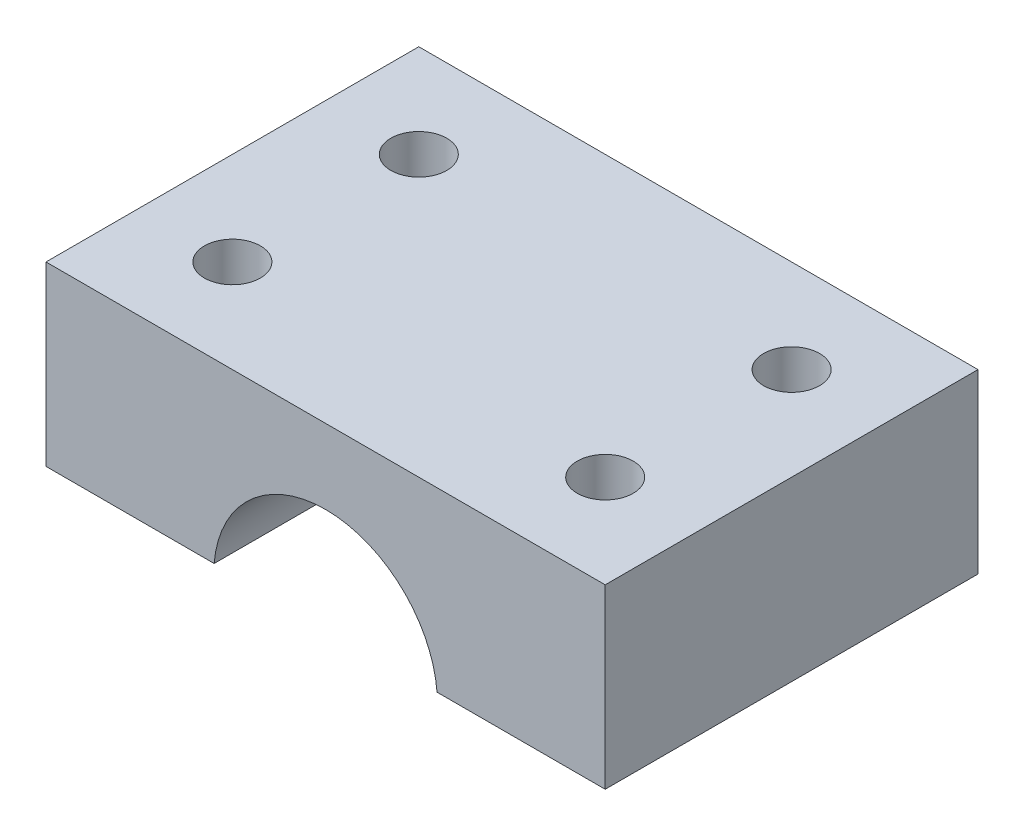
from build123d import *

# Parameters (mm, degrees)
BOSS_EXTRU_1_DEPTH      = 20
ESQUISSE3_R             = 1.5
ENL_V_MAT_EXTRU_1_DEPTH = 10


with BuildPart() as part:
    # Esquisse2 → Boss.-Extru.1 (new body)
    with BuildSketch(Plane.XY):
        with BuildLine():
            Line((-15, 0.5), (-15, 10))
            Line((-15, 10), (15, 10))
            Line((15, 10), (15, 0.5))
            Line((15, 0.5), (5.979130372, 0.5))
            ThreePointArc((5.979130372, 0.5), (0, 6), (-5.979130372, 0.5))
            Line((-5.979130372, 0.5), (-15, 0.5))
        make_face()
    extrude(amount=BOSS_EXTRU_1_DEPTH)

    # Esquisse3 → Enlèv. mat.-Extru.1 (cut)
    with BuildSketch(Plane(origin=(0, 10, 0), x_dir=(1, 0, 0), z_dir=(0, 1, 0))):
        with Locations((-10, -5)):
            Circle(ESQUISSE3_R)
        with Locations((10, -5)):
            Circle(ESQUISSE3_R)
        with Locations((-10, -15)):
            Circle(ESQUISSE3_R)
        with Locations((10, -15)):
            Circle(ESQUISSE3_R)
    extrude(amount=-ENL_V_MAT_EXTRU_1_DEPTH, mode=Mode.SUBTRACT)


solid = part.part
